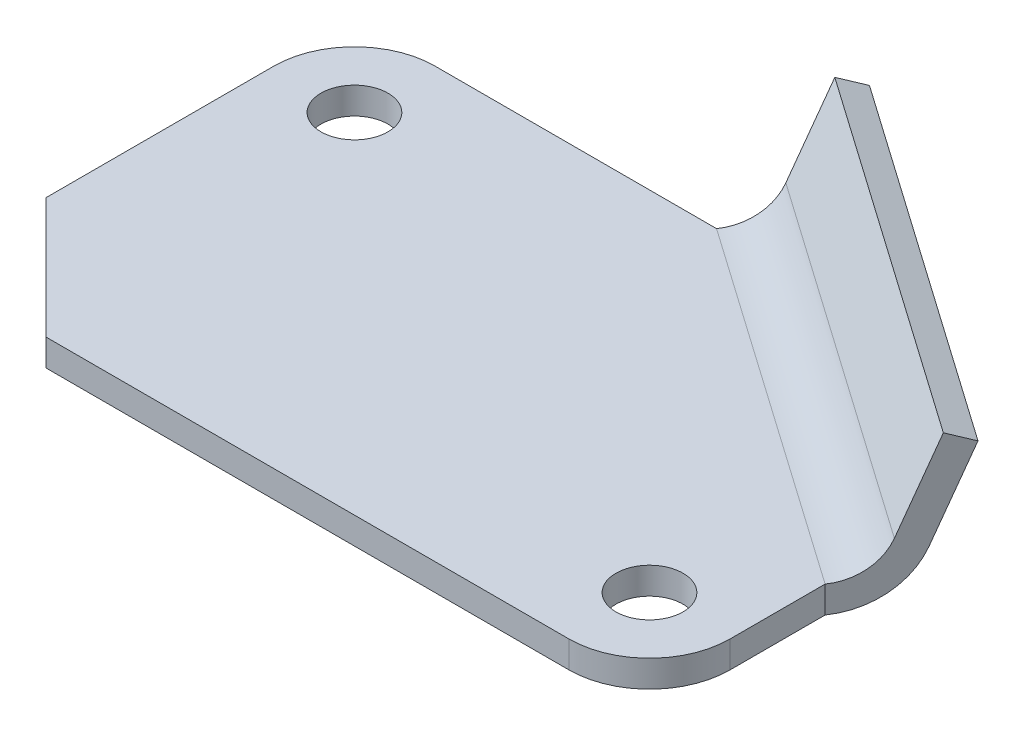
from build123d import *

# Parameters (mm, degrees)
SKETCH1_R           = 5
BOSS_EXTRUDE1_DEPTH = 4
BOSS_EXTRUDE2_DEPTH = 65.921828


with BuildPart() as part:
    # Sketch1 → Boss-Extrude1 (new body)
    with BuildSketch(Plane(origin=(0, 0, 0), x_dir=(1, 0, 0), z_dir=(0, 1, 0))):
        with BuildLine():
            Line((-54, -14), (-36, -32))
            Line((-36, -32), (42, -32))
            ThreePointArc((42, -32), (50.485281374, -28.485281374), (54, -20))
            Line((54, -20), (54, -5.811207063))
            Line((54, -5.811207063), (0, 32))
            Line((0, 32), (-42, 32))
            ThreePointArc((-42, 32), (-50.485281374, 28.485281374), (-54, 20))
            Line((-54, 20), (-54, -14))
        make_face()
        with Locations((-42, 20)):
            Circle(SKETCH1_R, mode=Mode.SUBTRACT)
        with Locations((42, -20)):
            Circle(SKETCH1_R, mode=Mode.SUBTRACT)
    extrude(amount=BOSS_EXTRUDE1_DEPTH)

    # Sketch2 → Boss-Extrude2 (add)
    with BuildSketch(Plane(origin=(38.964918067, 0, 27.283529357), x_dir=(0, -1, 0), z_dir=(0.819152044, 0, 0.573576436))):
        with BuildLine():
            Line((-9.003147253, 33.630336254), (-21.983721217, 38.874828562))
            Line((-21.983721217, 38.874828562), (-20.485294843, 42.58356398))
            Line((-20.485294843, 42.58356398), (-7.504720879, 37.339071672))
            ThreePointArc((-7.504720879, 37.339071672), (-2.051549129, 32.923180259), (0, 26.212865417))
            Line((0, 26.212865417), (-4, 26.212865417))
            ThreePointArc((-4, 26.212865417), (-5.36769942, 30.686408645), (-9.003147253, 33.630336254))
        make_face()
    extrude(amount=-BOSS_EXTRUDE2_DEPTH)


solid = part.part
